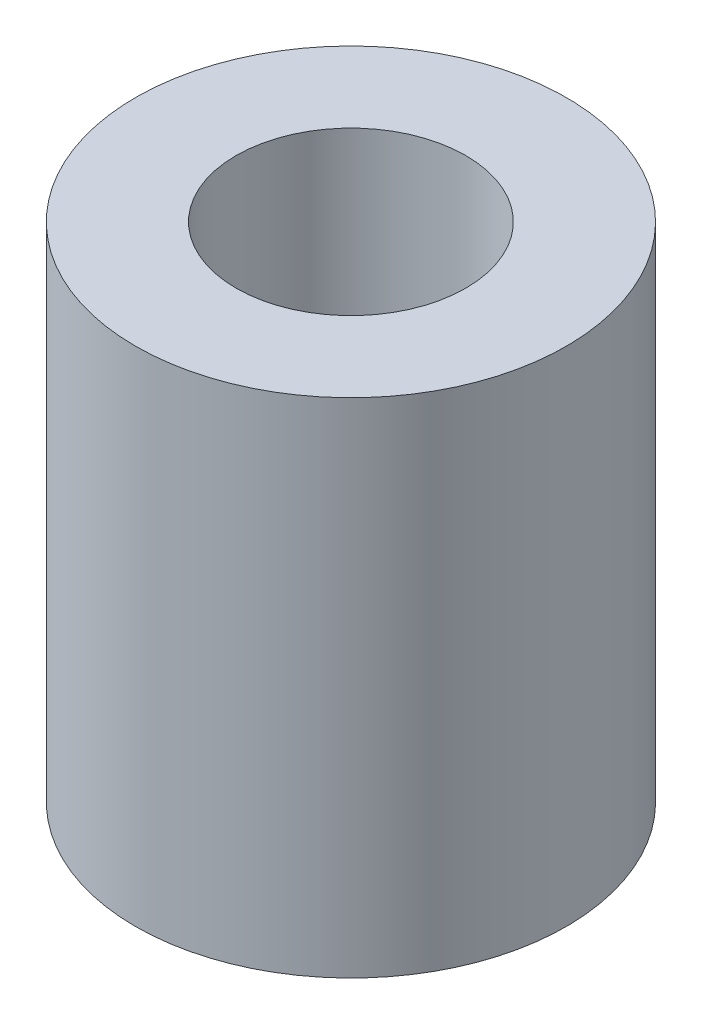
from build123d import *

# Parameters (mm, degrees)
SKETCH_1_R          = 15
SKETCH_1_R_2        = 3.5
EXTRUDE_1_DEPTH     = 35
SKETCH_2_R          = 3.5
CUT_EXTRUDE_1_DEPTH = 10
SKETCH_3_R          = 8
CUT_EXTRUDE_2_DEPTH = 32


with BuildPart() as part:
    # 草图1 → 凸台-拉伸1 (new body)
    with BuildSketch(Plane(origin=(0, 0, 0), x_dir=(1, 0, 0), z_dir=(0, 1, 0))):
        Circle(SKETCH_1_R)
        Circle(SKETCH_1_R_2, mode=Mode.SUBTRACT)
        Circle(SKETCH_1_R_2)
    extrude(amount=EXTRUDE_1_DEPTH)

    # 草图2 → 切除-拉伸1 (cut)
    with BuildSketch(Plane.XZ):
        Circle(SKETCH_2_R)
    extrude(amount=-CUT_EXTRUDE_1_DEPTH, mode=Mode.SUBTRACT)

    # 草图3 → 切除-拉伸2 (cut)
    with BuildSketch(Plane(origin=(0, 35, 0), x_dir=(1, 0, 0), z_dir=(0, 1, 0))):
        Circle(SKETCH_3_R)
    extrude(amount=-CUT_EXTRUDE_2_DEPTH, mode=Mode.SUBTRACT)


solid = part.part
